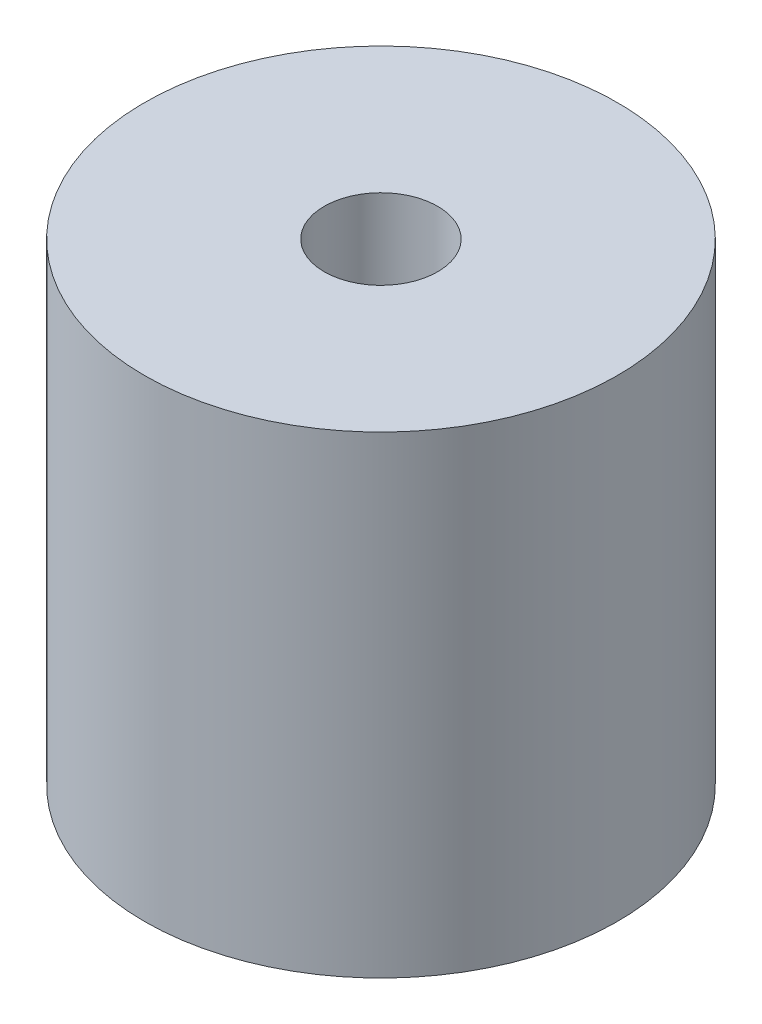
from build123d import *

# Parameters (mm, degrees)
SKETCH1_R           = 17.5
BOSS_EXTRUDE1_DEPTH = 35
SKETCH2_R           = 4.2
CUT_EXTRUDE1_DEPTH  = 10
SKETCH3_R           = 1.7
CUT_EXTRUDE2_DEPTH  = 26
CHAMFER1_SIZE       = 2.4892


with BuildPart() as part:
    # Sketch1 → Boss-Extrude1 (new body)
    with BuildSketch(Plane(origin=(0, 0, 0), x_dir=(1, 0, 0), z_dir=(0, 1, 0))):
        with Locations(Location((0, 0, 0), (0, 0, 270))):  # turned: the seam where the file's is
            Circle(SKETCH1_R)
    extrude(amount=BOSS_EXTRUDE1_DEPTH)

    # Sketch2 → Cut-Extrude1 (cut)
    with BuildSketch(Plane(origin=(0, 35, 0), x_dir=(1, 0, 0), z_dir=(0, 1, 0))):
        with Locations(Location((0, 0, 0), (0, 0, 270))):  # turned: the seam where the file's is
            Circle(SKETCH2_R)
    extrude(amount=-CUT_EXTRUDE1_DEPTH, mode=Mode.SUBTRACT)

    # Sketch3 → Cut-Extrude2 (cut, through all)
    with BuildSketch(Plane(origin=(0, 25, 0), x_dir=(1, 0, 0), z_dir=(0, 1, 0))):
        with Locations(Location((0, 0, 0), (0, 0, 270))):  # turned: the seam where the file's is
            Circle(SKETCH3_R)
    extrude(amount=-CUT_EXTRUDE2_DEPTH, mode=Mode.SUBTRACT)

    # Chamfer1
    chamfer1_edges = [part.edges().sort_by_distance(p)[0] for p in [
        (0, 25, -1.7),
    ]]
    chamfer(chamfer1_edges, length=CHAMFER1_SIZE)


solid = part.part
